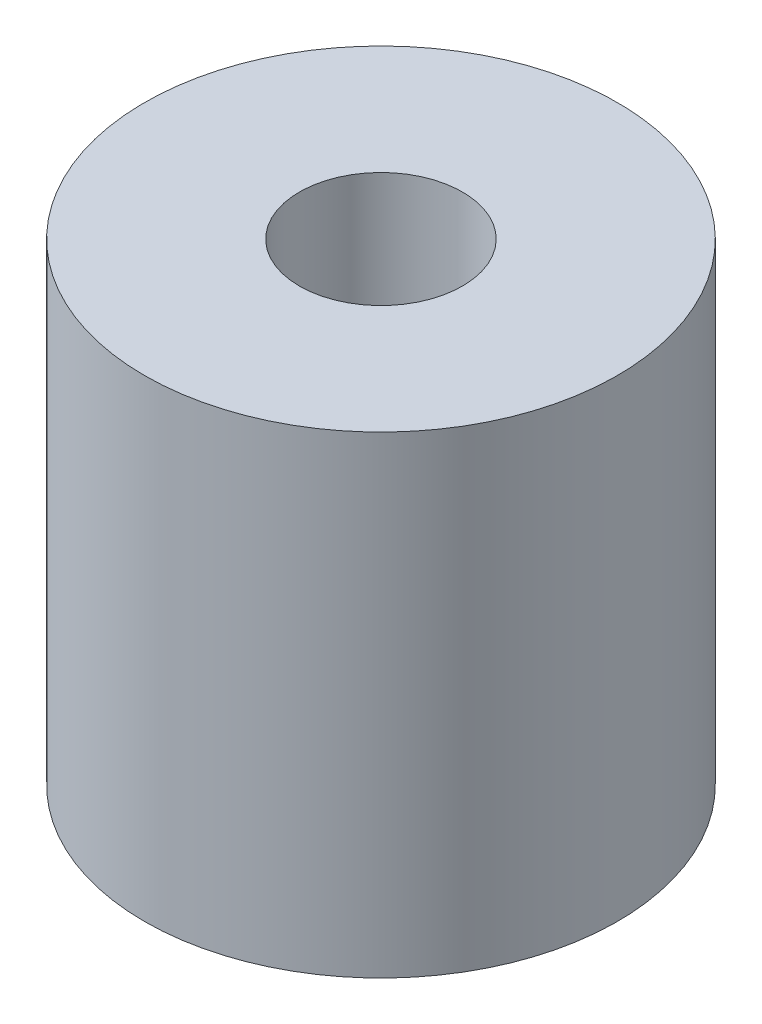
from build123d import *

# Parameters (mm, degrees)
SKETCH1_R           = 29
SKETCH1_R_2         = 10
BOSS_EXTRUDE1_DEPTH = 58


with BuildPart() as part:
    # Sketch1 → Boss-Extrude1 (new body)
    with BuildSketch(Plane(origin=(0, 0, 0), x_dir=(1, 0, 0), z_dir=(0, 1, 0))):
        Circle(SKETCH1_R)
        Circle(SKETCH1_R_2, mode=Mode.SUBTRACT)
    extrude(amount=BOSS_EXTRUDE1_DEPTH)


solid = part.part
